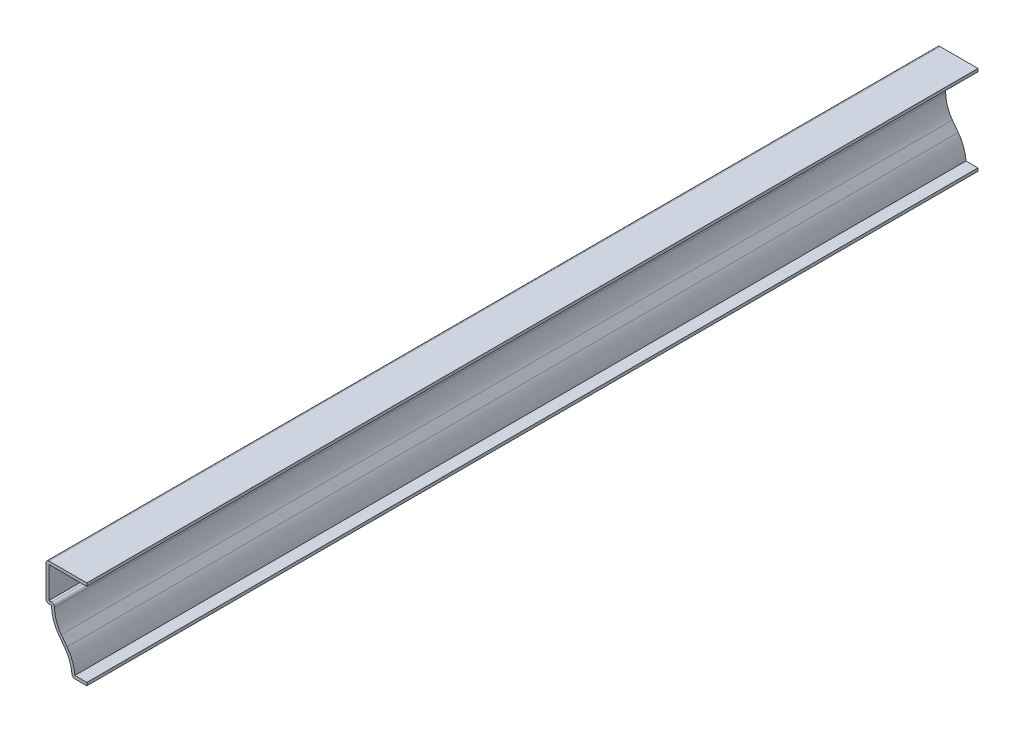
from build123d import *

# Parameters (mm, degrees)
EXTRUDE_THIN1_DEPTH = 381
FILLET1_R           = 1.27


with BuildPart() as part:
    # Sketch1 → Extrude-Thin1 (new body)
    with BuildSketch(Plane.XY):
        with BuildLine():
            Line((0, 0), (-6.35, 0))
            ThreePointArc((-6.35, 0), (-7.150715566, 4.970497036), (-9.471846695, 9.438084357))
            Line((-9.471846695, 9.438084357), (-11.959403305, 12.786915643))
            ThreePointArc((-11.959403305, 12.786915643), (-14.280534434, 17.254502964), (-15.08125, 22.225))
            Line((-15.08125, 22.225), (-17.4625, 22.225))
            Line((-17.4625, 22.225), (-17.4625, 38.1))
            Line((-17.4625, 38.1), (0, 38.1))
            Line((0, 38.1), (0, 36.83))
            Line((0, 36.83), (-16.1925, 36.83))
            Line((-16.1925, 36.83), (-16.1925, 23.495))
            Line((-16.1925, 23.495), (-13.75574743, 23.495))
            ThreePointArc((-13.75574743, 23.495), (-13.261207377, 18.261141502), (-10.939897249, 13.544218358))
            Line((-10.939897249, 13.544218358), (-8.45234064, 10.195387073))
            ThreePointArc((-8.45234064, 10.195387073), (-6.155730596, 5.968907892), (-5.127232377, 1.27))
            Line((-5.127232377, 1.27), (0, 1.27))
            Line((0, 1.27), (0, 0))
        make_face()
    extrude(amount=-EXTRUDE_THIN1_DEPTH)

    # Fillet1
    fillet1_edges = [part.edges().sort_by_distance(p)[0] for p in [
        (-13.75574743, 23.495, -190.5),
        (-6.35, 0, -190.5),
        (-17.4625, 22.225, -190.5),
        (-17.4625, 38.1, -190.5),
    ]]
    fillet(fillet1_edges, radius=FILLET1_R)


solid = part.part
